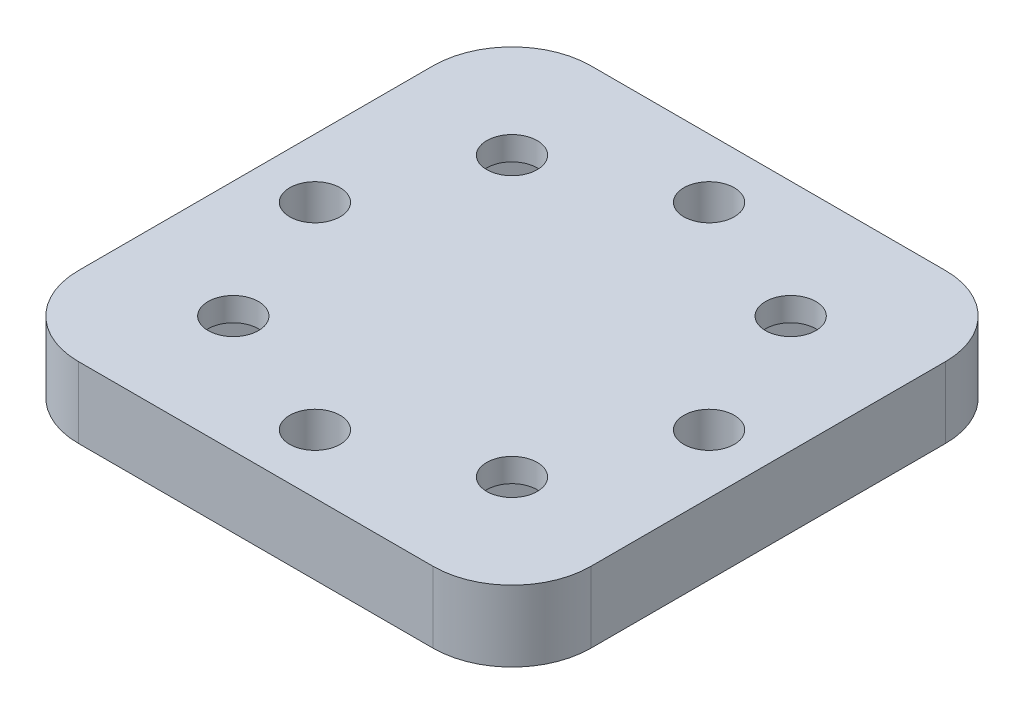
from build123d import *

# Parameters (mm, degrees)
SKETCH_1_W          = 65
SKETCH_1_H          = 65
EXTRUDE_1_DEPTH     = 9
SKETCH_2_R          = 3.2
CUT_EXTRUDE_1_DEPTH = 9
CUT_EXTRUDE_2_DEPTH = 6
FILLET_1_R          = 10


with BuildPart() as part:
    # 스케치1 → 보스-돌출1 (new body)
    with BuildSketch(Plane(origin=(0, 0, 0), x_dir=(1, 0, 0), z_dir=(0, 1, 0))):
        Rectangle(SKETCH_1_W, SKETCH_1_H)
    extrude(amount=EXTRUDE_1_DEPTH)

    # 스케치2 → 컷-돌출1 (cut)
    with BuildSketch(Plane(origin=(0, 9, 0), x_dir=(1, 0, 0), z_dir=(0, 1, 0))):
        with Locations((-17.67766953, 17.67766953)):
            Circle(SKETCH_2_R)
        with Locations((17.67766953, -17.67766953)):
            Circle(SKETCH_2_R)
        with Locations((-17.67766953, -17.67766953)):
            Circle(SKETCH_2_R)
        with Locations((17.67766953, 17.67766953)):
            Circle(SKETCH_2_R)
        with Locations((0, 25)):
            Circle(SKETCH_2_R)
        with Locations((25, 0)):
            Circle(SKETCH_2_R)
        with Locations((0, -25)):
            Circle(SKETCH_2_R)
        with Locations((-25, 0)):
            Circle(SKETCH_2_R)
    extrude(amount=-CUT_EXTRUDE_1_DEPTH, mode=Mode.SUBTRACT)

    # 스케치3 → 컷-돌출2 (cut)
    with BuildSketch(Plane.XZ):
        Polygon((-25.031580054, 17.67766953), (-17.67766953, 10.323759005), (-10.323759005, 17.67766953), (-17.67766953, 25.031580054), align=None)
        Polygon((10.323759005, 17.67766953), (17.67766953, 10.323759005), (25.031580054, 17.67766953), (17.67766953, 25.031580054), align=None)
        Polygon((10.323759005, -17.67766953), (17.67766953, -25.031580054), (25.031580054, -17.67766953), (17.67766953, -10.323759005), align=None)
        Polygon((-25.031580054, -17.67766953), (-17.67766953, -25.031580054), (-10.323759005, -17.67766953), (-17.67766953, -10.323759005), align=None)
    extrude(amount=-CUT_EXTRUDE_2_DEPTH, mode=Mode.SUBTRACT)

    # 필렛1
    fillet_1_edges = [part.edges().sort_by_distance(p)[0] for p in [
        (-32.5, 4.5, -32.5),
        (32.5, 4.5, -32.5),
        (32.5, 4.5, 32.5),
        (-32.5, 4.5, 32.5),
    ]]
    fillet(fillet_1_edges, radius=FILLET_1_R)


solid = part.part
